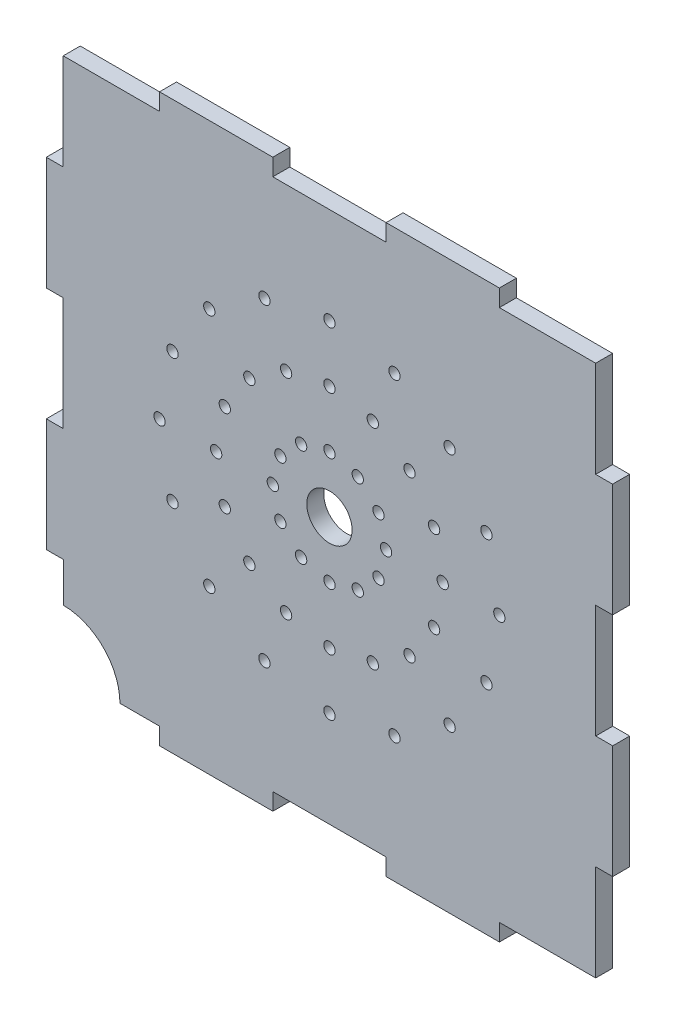
from build123d import *

# Parameters (mm, degrees)
SKETCH_1_R      = 1
SKETCH_1_R_2    = 4
EXTRUDE_1_DEPTH = 3


with BuildPart() as part:
    # 草图1 → 凸台-拉伸1 (new body)
    with BuildSketch(Plane.XY):
        with BuildLine():
            Line((-10, 47.024429381), (10, 47.024429381))
            Line((10, 47.024429381), (10, 50.024429381))
            Line((10, 50.024429381), (30, 50.024429381))
            Line((30, 50.024429381), (30, 47.024429381))
            Line((30, 47.024429381), (47, 47.024429381))
            Line((47, 47.024429381), (47, 30.024429381))
            Line((47, 30.024429381), (49.989371297, 30.024429381))
            Line((49.989371297, 30.024429381), (49.989371297, 10.024429381))
            Line((49.989371297, 10.024429381), (47.010628703, 10.024429381))
            Line((47.010628703, 10.024429381), (47.010628703, -9.975570619))
            Line((47.010628703, -9.975570619), (50.010629304, -9.975570619))
            Line((50.010629304, -9.975570619), (50.010629304, -29.975570018))
            Line((50.010629304, -29.975570018), (47.010629304, -29.975570018))
            Line((47.010629304, -29.975570018), (47.010629304, -46.975570018))
            Line((47.010629304, -46.975570018), (30.010628703, -46.975570018))
            Line((30.010628703, -46.975570018), (30.010628703, -49.975570619))
            Line((30.010628703, -49.975570619), (10.010628703, -49.975570619))
            Line((10.010628703, -49.975570619), (10.010628703, -46.975570619))
            Line((10.010628703, -46.975570619), (-9.989371297, -46.975570619))
            Line((-9.989371297, -46.975570619), (-9.989371297, -49.975570619))
            Line((-9.989371297, -49.975570619), (-29.989371297, -49.975570619))
            Line((-29.989371297, -49.975570619), (-29.989371297, -46.975570619))
            Line((-29.989371297, -46.975570619), (-36.989371297, -46.975570619))
            ThreePointArc((-36.989371297, -46.975570619), (-39.918303485, -39.904502807), (-46.989371297, -36.975570619))
            Line((-46.989371297, -36.975570619), (-46.989371297, -29.975570619))
            Line((-46.989371297, -29.975570619), (-49.989371297, -29.975570619))
            Line((-49.989371297, -29.975570619), (-49.989371297, -9.975570619))
            Line((-49.989371297, -9.975570619), (-47.010628703, -9.975570619))
            Line((-47.010628703, -9.975570619), (-47.010628703, 10.024429381))
            Line((-47.010628703, 10.024429381), (-49.989371297, 10.024429381))
            Line((-49.989371297, 10.024429381), (-49.989371297, 30.024429381))
            Line((-49.989371297, 30.024429381), (-47, 30.024429381))
            Line((-47, 30.024429381), (-47, 47.024429381))
            Line((-47, 47.024429381), (-30, 47.024429381))
            Line((-30, 47.024429381), (-30, 50.024429381))
            Line((-30, 50.024429381), (-10, 50.024429381))
            Line((-10, 50.024429381), (-10, 47.024429381))
        make_face()
        with Locations((10, 0)):
            Circle(SKETCH_1_R, mode=Mode.SUBTRACT)
        with Locations((20, 0)):
            Circle(SKETCH_1_R, mode=Mode.SUBTRACT)
        with Locations((30, 0)):
            Circle(SKETCH_1_R, mode=Mode.SUBTRACT)
        with Locations((18.477666771, -7.653285964)):
            Circle(SKETCH_1_R, mode=Mode.SUBTRACT)
        with Locations((27.716462096, -11.480120288)):
            Circle(SKETCH_1_R, mode=Mode.SUBTRACT)
        with Locations((14.142428517, -14.141428517)):
            Circle(SKETCH_1_R, mode=Mode.SUBTRACT)
        with Locations((21.213496329, -21.212496329)):
            Circle(SKETCH_1_R, mode=Mode.SUBTRACT)
        with Locations((7.654285964, -18.476666771)):
            Circle(SKETCH_1_R, mode=Mode.SUBTRACT)
        with Locations((11.481120288, -27.715462096)):
            Circle(SKETCH_1_R, mode=Mode.SUBTRACT)
        with Locations((0.001, -19.999)):
            Circle(SKETCH_1_R, mode=Mode.SUBTRACT)
        with Locations((0.001, -29.999)):
            Circle(SKETCH_1_R, mode=Mode.SUBTRACT)
        with Locations((-7.652285964, -18.476666771)):
            Circle(SKETCH_1_R, mode=Mode.SUBTRACT)
        with Locations((-11.479120288, -27.715462096)):
            Circle(SKETCH_1_R, mode=Mode.SUBTRACT)
        with Locations((-14.140428517, -14.141428517)):
            Circle(SKETCH_1_R, mode=Mode.SUBTRACT)
        with Locations((-21.211496329, -21.212496329)):
            Circle(SKETCH_1_R, mode=Mode.SUBTRACT)
        with Locations((-18.475666771, -7.653285964)):
            Circle(SKETCH_1_R, mode=Mode.SUBTRACT)
        with Locations((-27.714462096, -11.480120288)):
            Circle(SKETCH_1_R, mode=Mode.SUBTRACT)
        with Locations((-19.998, 0)):
            Circle(SKETCH_1_R, mode=Mode.SUBTRACT)
        with Locations((-29.998, 0)):
            Circle(SKETCH_1_R, mode=Mode.SUBTRACT)
        with Locations((-18.475666771, 7.653285964)):
            Circle(SKETCH_1_R, mode=Mode.SUBTRACT)
        with Locations((-27.714462096, 11.480120288)):
            Circle(SKETCH_1_R, mode=Mode.SUBTRACT)
        with Locations((-14.140428517, 14.141428517)):
            Circle(SKETCH_1_R, mode=Mode.SUBTRACT)
        with Locations((-21.211496329, 21.212496329)):
            Circle(SKETCH_1_R, mode=Mode.SUBTRACT)
        with Locations((-7.652285964, 18.476666771)):
            Circle(SKETCH_1_R, mode=Mode.SUBTRACT)
        with Locations((-11.479120288, 27.715462096)):
            Circle(SKETCH_1_R, mode=Mode.SUBTRACT)
        with Locations((0.001, 19.999)):
            Circle(SKETCH_1_R, mode=Mode.SUBTRACT)
        with Locations((0.001, 29.999)):
            Circle(SKETCH_1_R, mode=Mode.SUBTRACT)
        with Locations((7.654285964, 18.476666771)):
            Circle(SKETCH_1_R, mode=Mode.SUBTRACT)
        with Locations((11.481120288, 27.715462096)):
            Circle(SKETCH_1_R, mode=Mode.SUBTRACT)
        with Locations((14.142428517, 14.141428517)):
            Circle(SKETCH_1_R, mode=Mode.SUBTRACT)
        with Locations((21.213496329, 21.212496329)):
            Circle(SKETCH_1_R, mode=Mode.SUBTRACT)
        with Locations((18.477666771, 7.653285964)):
            Circle(SKETCH_1_R, mode=Mode.SUBTRACT)
        with Locations((27.716462096, 11.480120288)):
            Circle(SKETCH_1_R, mode=Mode.SUBTRACT)
        with Locations((8.660254038, -5)):
            Circle(SKETCH_1_R, mode=Mode.SUBTRACT)
        with Locations((5, -8.660254038)):
            Circle(SKETCH_1_R, mode=Mode.SUBTRACT)
        with Locations((0, -10)):
            Circle(SKETCH_1_R, mode=Mode.SUBTRACT)
        with Locations((-5, -8.660254038)):
            Circle(SKETCH_1_R, mode=Mode.SUBTRACT)
        with Locations((-8.660254038, -5)):
            Circle(SKETCH_1_R, mode=Mode.SUBTRACT)
        with Locations((-10, 0)):
            Circle(SKETCH_1_R, mode=Mode.SUBTRACT)
        with Locations((-8.660254038, 5)):
            Circle(SKETCH_1_R, mode=Mode.SUBTRACT)
        with Locations((-5, 8.660254038)):
            Circle(SKETCH_1_R, mode=Mode.SUBTRACT)
        with Locations((0, 10)):
            Circle(SKETCH_1_R, mode=Mode.SUBTRACT)
        with Locations((5, 8.660254038)):
            Circle(SKETCH_1_R, mode=Mode.SUBTRACT)
        with Locations((8.660254038, 5)):
            Circle(SKETCH_1_R, mode=Mode.SUBTRACT)
        Circle(SKETCH_1_R_2, mode=Mode.SUBTRACT)
    extrude(amount=EXTRUDE_1_DEPTH)


solid = part.part
